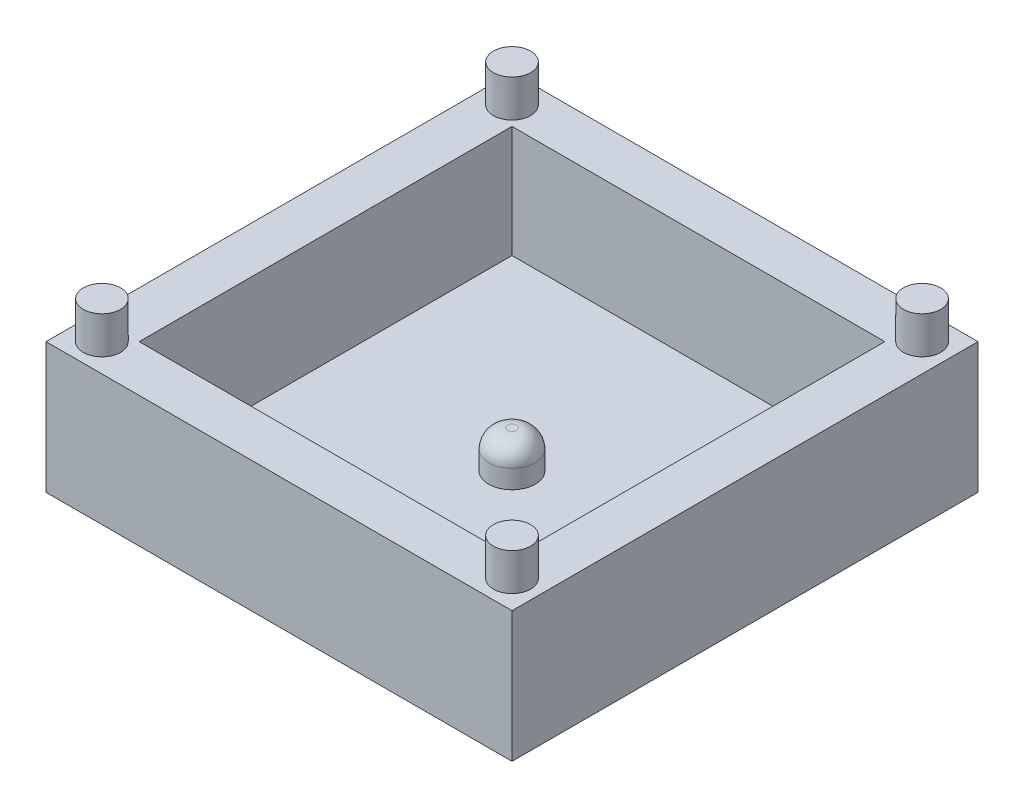
from build123d import *

# Parameters (mm, degrees)
SKETCH1_W           = 25
SKETCH1_H           = 25
BOSS_EXTRUDE1_DEPTH = 7
SKETCH2_W           = 20
SKETCH2_H           = 20
CUT_EXTRUDE1_DEPTH  = 6
SKETCH3_R           = 1.25
BOSS_EXTRUDE2_DEPTH = 2
FILLET1_R           = 1
SKETCH4_R           = 1
BOSS_EXTRUDE3_DEPTH = 2


with BuildPart() as part:
    # Sketch1 → Boss-Extrude1 (new body)
    with BuildSketch(Plane(origin=(0, 0, 0), x_dir=(1, 0, 0), z_dir=(0, 1, 0))):
        Rectangle(SKETCH1_W, SKETCH1_H)
    extrude(amount=BOSS_EXTRUDE1_DEPTH)

    # Sketch2 → Cut-Extrude1 (cut)
    with BuildSketch(Plane(origin=(0, 7, 0), x_dir=(1, 0, 0), z_dir=(0, 1, 0))):
        Rectangle(SKETCH2_W, SKETCH2_H)
    extrude(amount=-CUT_EXTRUDE1_DEPTH, mode=Mode.SUBTRACT)

    # Sketch3 → Boss-Extrude2 (add)
    with BuildSketch(Plane(origin=(0, 1, 0), x_dir=(1, 0, 0), z_dir=(0, 1, 0))):
        Circle(SKETCH3_R)
    extrude(amount=BOSS_EXTRUDE2_DEPTH)

    # Fillet1
    fillet1_edges = [part.edges().sort_by_distance(p)[0] for p in [
        (-1.25, 3, 0),
    ]]
    fillet(fillet1_edges, radius=FILLET1_R)

    # Sketch4 → Boss-Extrude3 (add)
    with BuildSketch(Plane(origin=(0, 7, 0), x_dir=(1, 0, 0), z_dir=(0, 1, 0))):
        with Locations((-11, 11)):
            Circle(SKETCH4_R)
        with Locations((11, 11)):
            Circle(SKETCH4_R)
        with Locations((11, -11)):
            Circle(SKETCH4_R)
        with Locations((-11, -11)):
            Circle(SKETCH4_R)
    extrude(amount=BOSS_EXTRUDE3_DEPTH)


solid = part.part
